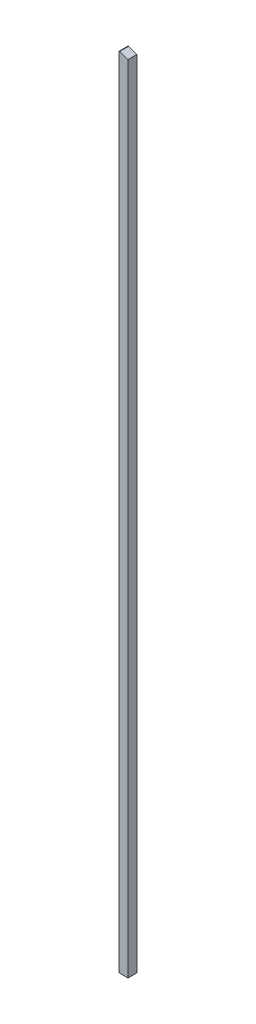
from build123d import *

# Parameters (mm, degrees)
SKETCH1_W           = 25.4
SKETCH1_H           = 25.4
BOSS_EXTRUDE1_DEPTH = 2286
CHAMFER1_SIZE       = 8.382
CHAMFER1_SIZE2      = 23.876


with BuildPart() as part:
    # Sketch1 → Boss-Extrude1 (new body)
    with BuildSketch(Plane(origin=(0, 0, 0), x_dir=(1, 0, 0), z_dir=(0, 1, 0))):
        with Locations((12.7, 12.7)):
            Rectangle(SKETCH1_W, SKETCH1_H)
    extrude(amount=BOSS_EXTRUDE1_DEPTH)

    # Chamfer1
    chamfer1_edges = [part.edges().sort_by_distance(p)[0] for p in [
        (25.4, 2286, -12.7),
    ]]
    chamfer1_side = [part.faces().sort_by_distance(p)[0] for p in [
        (25.4, 1143, -12.7),
    ]]
    chamfer(chamfer1_edges, length=CHAMFER1_SIZE, length2=CHAMFER1_SIZE2, reference=chamfer1_side[0])


solid = part.part
